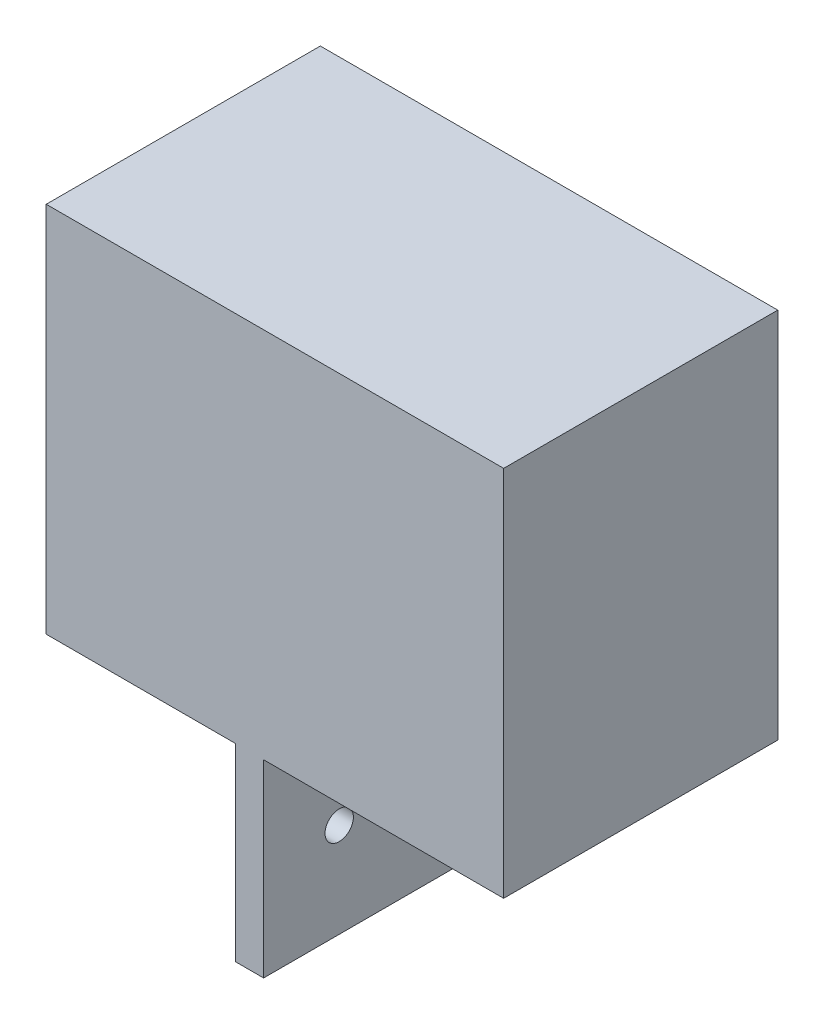
from build123d import *

# Parameters (mm, degrees)
SKETCH2_W           = 48.768
SKETCH2_H           = 50.038
SKETCH2_W_2         = 42.418
SKETCH2_H_2         = 42.418
BOSS_EXTRUDE1_DEPTH = 34.29
SKETCH4_W           = 48.768
SKETCH4_H           = 50.038
BOSS_EXTRUDE2_DEPTH = 2.54
SKETCH5_W           = 3.81
SKETCH5_H           = 25.4
BOSS_EXTRUDE3_DEPTH = 36.83
SKETCH6_W           = 12.7
SKETCH6_H           = 50.038
BOSS_EXTRUDE4_DEPTH = 36.83
SKETCH7_R           = 1.905
CUT_EXTRUDE1_DEPTH  = 30.21


with BuildPart() as part:
    # Sketch2 → Boss-Extrude1 (new body)
    with BuildSketch(Plane.XY):
        with Locations((20.574, 21.209)):
            Rectangle(SKETCH2_W, SKETCH2_H)
        with Locations((21.209, 21.209)):
            Rectangle(SKETCH2_W_2, SKETCH2_H_2, mode=Mode.SUBTRACT)
    extrude(amount=BOSS_EXTRUDE1_DEPTH)

    # Sketch4 → Boss-Extrude2 (add)
    with BuildSketch(Plane.XY.offset(34.29)):
        with Locations((20.574, 21.209)):
            Rectangle(SKETCH4_W, SKETCH4_H)
    extrude(amount=BOSS_EXTRUDE2_DEPTH)

    # Sketch5 → Boss-Extrude3 (add)
    with BuildSketch(Plane(origin=(0, 0, 0), x_dir=(-1, 0, 0), z_dir=(0, 0, -1))):
        with Locations((-10.795, -16.51)):
            Rectangle(SKETCH5_W, SKETCH5_H)
    extrude(amount=-BOSS_EXTRUDE3_DEPTH)

    # Sketch6 → Boss-Extrude4 (add)
    with BuildSketch(Plane(origin=(0, 0, 0), x_dir=(-1, 0, 0), z_dir=(0, 0, -1))):
        with Locations((10.16, 21.209)):
            Rectangle(SKETCH6_W, SKETCH6_H)
    extrude(amount=-BOSS_EXTRUDE4_DEPTH)

    # Sketch7 → Cut-Extrude1 (cut, through all)
    with BuildSketch(Plane(origin=(12.7, 0, 0), x_dir=(0, 0, -1), z_dir=(1, 0, 0))):
        with Locations((-26.67, -16.51)):
            Circle(SKETCH7_R)
        with Locations((-10.16, -16.51)):
            Circle(SKETCH7_R)
    extrude(amount=-CUT_EXTRUDE1_DEPTH, mode=Mode.SUBTRACT)


solid = part.part
